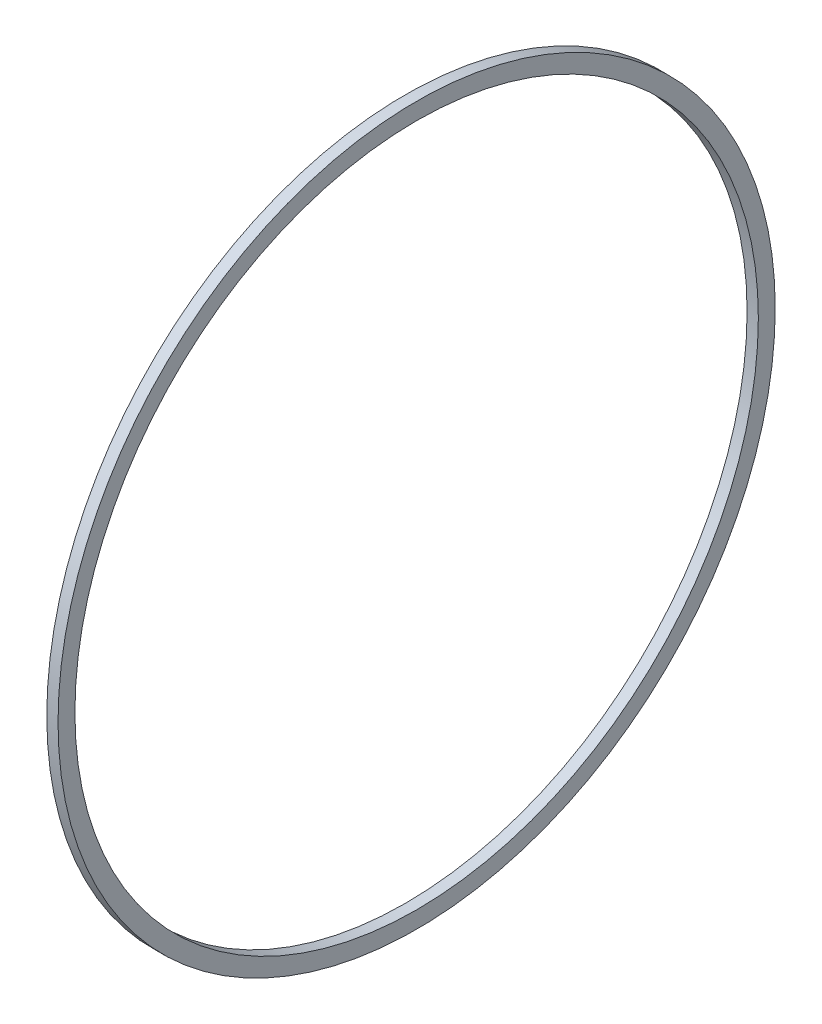
from build123d import *

# Parameters (mm, degrees)
SKETCH1_R           = 63.75
SKETCH1_R_2         = 60.75
BOSS_EXTRUDE1_DEPTH = 2


with BuildPart() as part:
    # Sketch1 → Boss-Extrude1 (new body)
    with BuildSketch(Plane(origin=(0, 0, 0), x_dir=(0, 0, -1), z_dir=(1, 0, 0))):
        Circle(SKETCH1_R)
        Circle(SKETCH1_R_2, mode=Mode.SUBTRACT)
    extrude(amount=BOSS_EXTRUDE1_DEPTH)


solid = part.part
